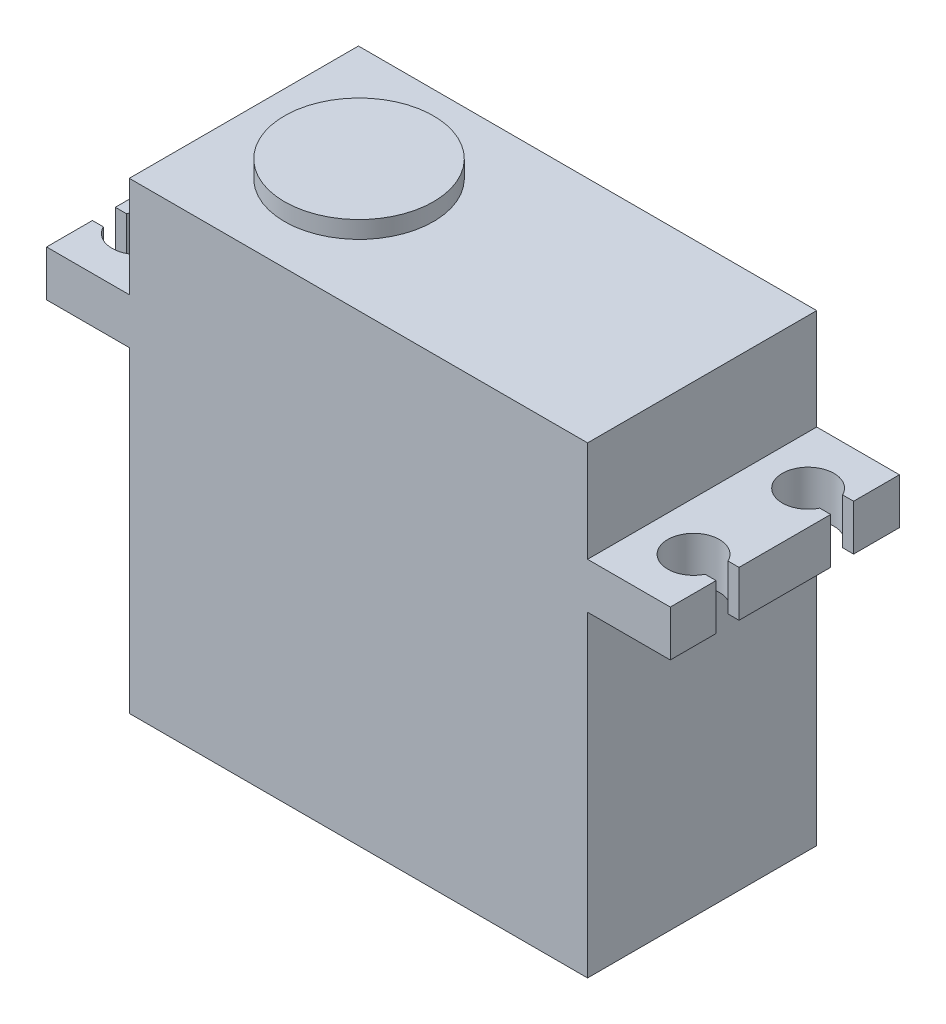
from build123d import *

# Parameters (mm, degrees)
SKETCH2_W             = 40
SKETCH2_H             = 20
BOSS_EXTRUDE1_DEPTH   = 27.65
SKETCH3_W             = 7
SKETCH3_H             = 4
BOSS_EXTRUDE2_DEPTH   = 5
SKETCH5_W             = 40
SKETCH5_H             = 20
BOSS_EXTRUDE5_DEPTH   = 12.8
SKETCH7_W             = 20
SKETCH7_H             = 4
BOSS_EXTRUDE6_DEPTH   = 7.22
CUT_EXTRUDE3_DEPTH    = 4
MIRROR11_COPY_1_DEPTH = 4
SKETCH9_R             = 6.5
BOSS_EXTRUDE8_DEPTH   = 1.5


with BuildPart() as part:
    # Sketch2 → Boss-Extrude1 (new body)
    with BuildSketch(Plane(origin=(0, 0, 0), x_dir=(1, 0, 0), z_dir=(0, 1, 0))):
        Rectangle(SKETCH2_W, SKETCH2_H)
    extrude(amount=BOSS_EXTRUDE1_DEPTH)

    # Sketch3 → Boss-Extrude2 (add)
    with BuildSketch(Plane.ZY.offset(20)):
        with Locations((0, 6)):
            Rectangle(SKETCH3_W, SKETCH3_H)
    extrude(amount=BOSS_EXTRUDE2_DEPTH)

    # Sketch5 → Boss-Extrude5 (add)
    with BuildSketch(Plane(origin=(0, 27.65, 0), x_dir=(1, 0, 0), z_dir=(0, 1, 0))):
        Rectangle(SKETCH5_W, SKETCH5_H)
    extrude(amount=BOSS_EXTRUDE5_DEPTH)

    # Sketch7 → Boss-Extrude6 (add)
    with BuildSketch(Plane.ZY.offset(20)):
        with Locations((0, 29.65)):
            Rectangle(SKETCH7_W, SKETCH7_H)
    boss_extrude6 = extrude(amount=BOSS_EXTRUDE6_DEPTH)

    # Sketch8 → Cut-Extrude3 (cut)
    with BuildSketch(Plane(origin=(0, 31.65, 0), x_dir=(1, 0, 0), z_dir=(0, 1, 0))):
        with BuildLine():
            Line((-26.265564437, 6), (-27.22, 6))
            Line((-27.22, 6), (-27.22, 4))
            Line((-27.22, 4), (-26.265564437, 4))
            ThreePointArc((-26.265564437, 4), (-22, 5), (-26.265564437, 6))
        make_face()
    cut_extrude3 = extrude(amount=-CUT_EXTRUDE3_DEPTH, mode=Mode.SUBTRACT)

    # Mirror10: Cut-Extrude3 across plane
    add(cut_extrude3.mirror(Plane.XY), mode=Mode.SUBTRACT)

    # Mirror11: Boss-Extrude6, Cut-Extrude3 across plane
    add(boss_extrude6.mirror(Plane(origin=(0, 0, 0), x_dir=(0, 0, 1), z_dir=(1, 0, 0))))
    add(cut_extrude3.mirror(Plane(origin=(0, 0, 0), x_dir=(0, 0, 1), z_dir=(1, 0, 0))), mode=Mode.SUBTRACT)

    # Mirror11 copy 1 sketch → Mirror11 copy 1 (cut)
    with BuildSketch(Plane(origin=(0, 31.65, 0), x_dir=(-1, 0, 0), z_dir=(0, 1, 0))):
        with BuildLine():
            Line((-26.265564437, 6), (-27.22, 6))
            Line((-27.22, 6), (-27.22, 4))
            Line((-27.22, 4), (-26.265564437, 4))
            ThreePointArc((-26.265564437, 4), (-22, 5), (-26.265564437, 6))
        make_face()
    extrude(amount=-MIRROR11_COPY_1_DEPTH, mode=Mode.SUBTRACT)

    # Sketch9 → Boss-Extrude8 (add)
    with BuildSketch(Plane(origin=(0, 40.45, 0), x_dir=(1, 0, 0), z_dir=(0, 1, 0))):
        with Locations(Location((-9.95, 0, 0), (0, 0, 270))):
            Circle(SKETCH9_R)
    extrude(amount=BOSS_EXTRUDE8_DEPTH)


solid = part.part
